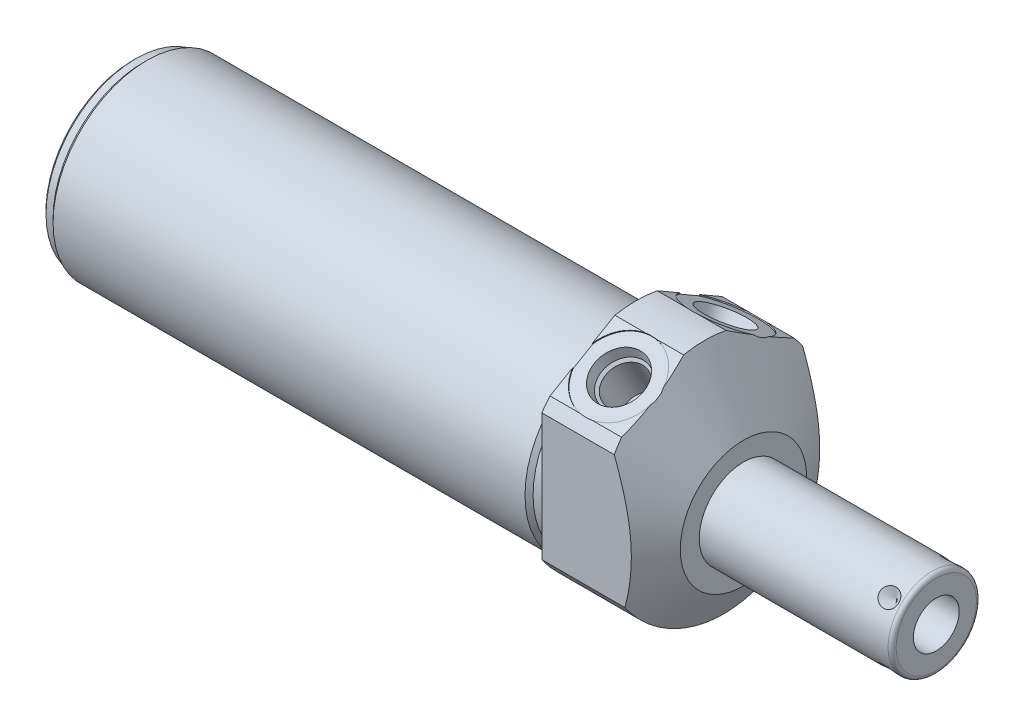
from build123d import *

# Parameters (mm, degrees)
SKETCH1_R           = 28.575
EXTRUDE1_DEPTH      = 27.0002
EXTRUDE1_DEPTH_BACK = 126.5428
CUT_EXTRUDE1_REACH  = 128.543
SKETCH2_R           = 28.575
SKETCH2_R_2         = 23.622
CUT_EXTRUDE3_START  = -27.0002
CUT_EXTRUDE3_DEPTH  = 27.0002
SKETCH18_R          = 9.525
CUT_EXTRUDE4_DEPTH  = 0.254
SKETCH19_R          = 9.525
CUT_EXTRUDE5_DEPTH  = 0.254
CHAMFER1_SIZE       = 0.762
CIRPATTERN1_COUNT   = 4


with BuildPart() as part:
    # Sketch1 → Extrude1 (new body, two sides)
    with BuildSketch(Plane(origin=(0, 0, 0), x_dir=(0, 0, -1), z_dir=(1, 0, 0))) as extrude1_sk:
        Circle(SKETCH1_R)
    extrude(amount=EXTRUDE1_DEPTH)
    extrude(extrude1_sk.sketch, amount=-EXTRUDE1_DEPTH_BACK)

    # Sketch2 → Cut-Extrude1 (cut, up to next)
    with BuildSketch(Plane(origin=(0, 0, 0), x_dir=(0, 0, -1), z_dir=(1, 0, 0)), mode=Mode.PRIVATE) as cut_extrude1_sk1:
        Circle(SKETCH2_R)
        with Locations((0, -4.191)):
            Circle(SKETCH2_R_2, mode=Mode.SUBTRACT)
    cut_extrude1_tool1 = extrude(cut_extrude1_sk1.sketch, amount=-CUT_EXTRUDE1_REACH, mode=Mode.PRIVATE) & part.part
    add(cut_extrude1_tool1.solids().sort_by_distance((0, 0, 27.766777))[0], mode=Mode.SUBTRACT)

    # Sketch4 → Cut-Extrude3 (cut)
    with BuildSketch(Plane.ZY.offset(CUT_EXTRUDE3_START)):
        with BuildLine():
            Line((23.6855, -25.666178421), (23.6855, 17.476089577))
            Line((23.6855, 17.476089577), (0, 31.150919378))
            Line((0, 31.150919378), (-23.6855, 17.476089577))
            Line((-23.6855, 17.476089577), (-23.6855, -25.666178421))
            ThreePointArc((-23.6855, -25.666178421), (0, 34.925), (23.6855, -25.666178421))
        make_face()
    extrude(amount=CUT_EXTRUDE3_DEPTH, mode=Mode.SUBTRACT)

    # Sketch6 → Cut-Revolve2 (revolve, cut)
    with BuildSketch(Plane.XY, mode=Mode.PRIVATE) as cut_revolve2_sk:
        Polygon((0.750392661, 57.15), (27.0002, 11.684), (27.0002, 57.15), align=None)
    revolve(cut_revolve2_sk.sketch.rotate(Axis((-0.562097706, -4.191, 0), (1, 0, 0)), 270), axis=Axis((-0.562097706, -4.191, 0), (1, 0, 0)), mode=Mode.SUBTRACT)  # turned: the seam where the file's is

    # S2D0002 → Cut-Revolve3 (revolve, cut)
    with BuildSketch(Plane(origin=(9.0932, 23.136869081, 13.372742289), x_dir=(0, 0.5, -0.866025404), z_dir=(1, 0, 0))):
        Polygon((0, 0), (6.1849, 0), (5.642306865, -2.5527), (4.9784, -3.216606865), (4.9784, -13.462), (0, -13.462), align=None)
    revolve(axis=Axis((9.0932, 10.895513396, 6.305192289), (0, 0.866025404, 0.5)), mode=Mode.SUBTRACT)

    # Sketch8 → Cut-Revolve4 (revolve, cut)
    with BuildSketch(Plane(origin=(9.0932, 23.136869081, -13.372742289), x_dir=(0, -0.5, -0.866025404), z_dir=(1, 0, 0))):
        Polygon((0, 0), (6.1849, 0), (5.642306865, -2.5527), (4.9784, -3.216606865), (4.9784, -13.462), (0, -13.462), align=None)
    revolve(axis=Axis((9.0932, 10.895513396, -6.305192289), (0, 0.866025404, -0.5)), mode=Mode.SUBTRACT)

    # Sketch18 → Cut-Extrude4 (cut)
    with BuildSketch(Plane(origin=(0, 23.363189534, 13.488743766), x_dir=(1, 0, 0), z_dir=(0, 0.866025404, 0.5))):
        with Locations((9.0932, -0.0127)):
            Circle(SKETCH18_R)
    extrude(amount=-CUT_EXTRUDE4_DEPTH, mode=Mode.SUBTRACT)

    # Sketch19 → Cut-Extrude5 (cut)
    with BuildSketch(Plane(origin=(0, 23.363189534, -13.488743766), x_dir=(1, 0, 0), z_dir=(0, 0.866025404, -0.5))):
        with Locations((9.0932, 0.0127)):
            Circle(SKETCH19_R)
    extrude(amount=-CUT_EXTRUDE5_DEPTH, mode=Mode.SUBTRACT)

    # Sketch10 → Cut-Revolve6 (revolve, cut)
    with BuildSketch(Plane.XY, mode=Mode.PRIVATE) as cut_revolve6_sk:
        Polygon((0, 19.431), (0, 18.415), (-3.302, 18.415), (-4.318, 19.431), align=None)
    revolve(cut_revolve6_sk.sketch.rotate(Axis((-4.5339, -4.191, 0), (1, 0, 0)), 90), axis=Axis((-4.5339, -4.191, 0), (1, 0, 0)), mode=Mode.SUBTRACT)  # turned: the seam where the file's is

    # Sketch12 → Cut-Revolve8 (revolve, cut)
    with BuildSketch(Plane.XY, mode=Mode.PRIVATE) as cut_revolve8_sk:
        Polygon((-126.5428, 19.431), (-126.5428, 18.415), (-124.0028, 18.415), (-122.9868, 19.431), align=None)
    revolve(cut_revolve8_sk.sketch.rotate(Axis((-84.3026, -4.191, 0), (1, 0, 0)), 90), axis=Axis((-84.3026, -4.191, 0), (1, 0, 0)), mode=Mode.SUBTRACT)  # turned: the seam where the file's is

    # Chamfer1
    chamfer1_edges = [part.edges().sort_by_distance(p)[0] for p in [
        (-126.5428, -4.191, -22.606),
    ]]
    chamfer(chamfer1_edges, length=CHAMFER1_SIZE)

    # Sketch13 → Revolve1 (revolve)
    with BuildSketch(Plane(origin=(0, 0, 0), x_dir=(0, -1, 0), z_dir=(0, 0, 1)), mode=Mode.PRIVATE) as revolve1_sk:
        with BuildLine():
            Line((4.191, 27.0002), (4.191, 75.4888))
            Line((4.191, 75.4888), (14.2875, 75.4888))
            ThreePointArc((14.2875, 75.4888), (15.00592049, 75.19122049), (15.3035, 74.4728))
            Line((15.3035, 74.4728), (15.3035, 27.0002))
            Line((15.3035, 27.0002), (4.191, 27.0002))
        make_face()
    revolve(revolve1_sk.sketch.rotate(Axis((25.10663, -4.191, 0), (1, 0, 0)), 270), axis=Axis((25.10663, -4.191, 0), (1, 0, 0)))  # turned: the seam where the file's is

    # S2D0001 → Cut-Revolve9 (revolve, cut)
    with BuildSketch(Plane(origin=(64.8716, -9.9441, 0), x_dir=(0, -1, 0), z_dir=(0, 0, 1)), mode=Mode.PRIVATE) as cut_revolve9_sk:
        Polygon((0, 10.6172), (0, -6.4008), (-5.7531, -9.857611227), (-5.7531, 10.6172), align=None)
    revolve(cut_revolve9_sk.sketch.rotate(Axis((43.373048211, -4.191, 0), (1, 0, 0)), 270), axis=Axis((43.373048211, -4.191, 0), (1, 0, 0)), mode=Mode.SUBTRACT)  # turned: the seam where the file's is

    # Sketch16 → Cut-Revolve10 (revolve, cut)
    with BuildSketch(Plane(origin=(60.9092, 3.666724106, -7.857724106), x_dir=(-1, 0, 0), z_dir=(0, -0.707106781, -0.707106781)), mode=Mode.PRIVATE) as cut_revolve10_sk:
        Polygon((-10.6172, 0), (-8.2042, 0), (-10.6172, -2.413), align=None)
    cut_revolve10 = revolve(cut_revolve10_sk.sketch.rotate(Axis((71.5264, 0.494324135, -4.685324135), (0, 0.707106781, -0.707106781)), 90), axis=Axis((71.5264, 0.494324135, -4.685324135), (0, 0.707106781, -0.707106781)), mode=Mode.SUBTRACT)  # turned: the seam where the file's is

    # CirPattern1: Cut-Revolve10 ×4 about axis
    cirpattern1_axis = Axis((25.10663, -4.191, 0), (-1, 0, 0))
    for i in range(1, CIRPATTERN1_COUNT):
        add(cut_revolve10.rotate(cirpattern1_axis, i * 360 / CIRPATTERN1_COUNT), mode=Mode.SUBTRACT)


solid = part.part
